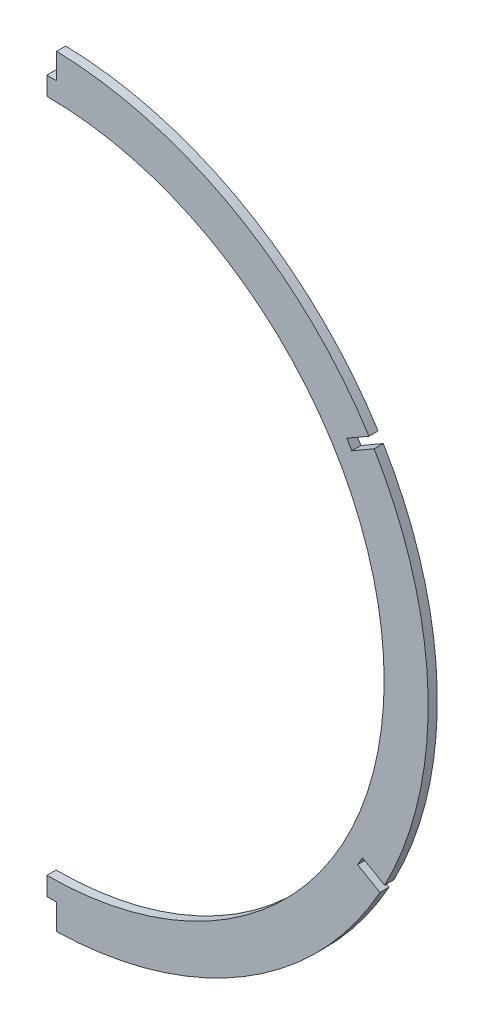
from build123d import *

# Parameters (mm, degrees)
SKETCH2_R           = 116.84
BOSS_EXTRUDE1_DEPTH = 1.5875
SKETCH3_W           = 232.210592103
SKETCH3_H           = 398.954583541
CUT_EXTRUDE1_DEPTH  = 133.08
CUT_EXTRUDE2_DEPTH  = 4.175


with BuildPart() as part:
    # Sketch2 → Boss-Extrude1 (new body, symmetric)
    with BuildSketch(Plane.XY):
        with BuildLine():
            ThreePointArc((-1.651, 128.513680847), (-113.443755652, 64.087482344), (-116.974071472, -64.89271823))
            ThreePointArc((-116.974071472, -64.89271823), (-116.588202689, -65.623039511), (-116.197774242, -66.350933404))
            ThreePointArc((-116.197774242, -66.350933404), (-115.802941233, -67.076116512), (-115.403582459, -67.798817153))
            ThreePointArc((-115.403582459, -67.798817153), (0, -135.636), (115.403582459, -67.798817153))
            ThreePointArc((115.403582459, -67.798817153), (115.802941375, -67.076116254), (116.197774523, -66.350932884))
            ThreePointArc((116.197774523, -66.350932884), (116.588202828, -65.62303925), (116.974071472, -64.89271823))
            ThreePointArc((116.974071472, -64.89271823), (113.443755652, 64.087482344), (1.651, 128.513680847))
            ThreePointArc((1.651, 128.513680847), (0.825516124, 128.521420187), (0, 128.524))
            ThreePointArc((0, 128.524), (-0.825516124, 128.521420187), (-1.651, 128.513680847))
        make_face()
        with Locations((0, -3.556)):
            Circle(SKETCH2_R, mode=Mode.SUBTRACT)
    extrude(amount=BOSS_EXTRUDE1_DEPTH, both=True)

    # Sketch3 → Cut-Extrude1 (cut, through all)
    with BuildSketch(Plane(origin=(0, 0, 0), x_dir=(0, 0, -1), z_dir=(1, 0, 0))):
        with Locations((6.714523145, -6.913261573)):
            Rectangle(SKETCH3_W, SKETCH3_H)
    extrude(amount=-CUT_EXTRUDE1_DEPTH, mode=Mode.SUBTRACT)

    # Sketch4 → Cut-Extrude2 (cut, through all)
    with BuildSketch(Plane.XY.offset(1.5875)):
        with BuildLine():
            Line((0, 119.634), (3.3782, 119.634))
            Line((3.3782, 119.634), (3.3782, 128.480790951))
            ThreePointArc((3.3782, 128.480790951), (1.689238161, 128.513197296), (0, 128.524))
            Line((0, 128.524), (0, 119.634))
        make_face()
        with BuildLine():
            ThreePointArc((113.357263981, 64.23232571), (112.480734843, 65.677017334), (111.585794735, 67.110376823))
            Line((111.585794735, 67.110376823), (103.931466898, 62.691148586))
            Line((103.931466898, 62.691148586), (105.620566898, 59.765541567))
            Line((105.620566898, 59.765541567), (113.357263981, 64.23232571))
        make_face()
        with BuildLine():
            ThreePointArc((115.385044136, -67.832107456), (116.197919214, -66.350665143), (116.99177489, -64.858944531))
            Line((116.99177489, -64.858944531), (109.337447053, -60.439716293))
            Line((109.337447053, -60.439716293), (107.648347053, -63.365323312))
            Line((107.648347053, -63.365323312), (115.385044136, -67.832107456))
        make_face()
        with BuildLine():
            ThreePointArc((0, -135.636), (1.689238161, -135.625197296), (3.3782, -135.592790951))
            Line((3.3782, -135.592790951), (3.3782, -126.746))
            Line((3.3782, -126.746), (0, -126.746))
            Line((0, -126.746), (0, -135.636))
        make_face()
    extrude(amount=-CUT_EXTRUDE2_DEPTH, mode=Mode.SUBTRACT)


solid = part.part
